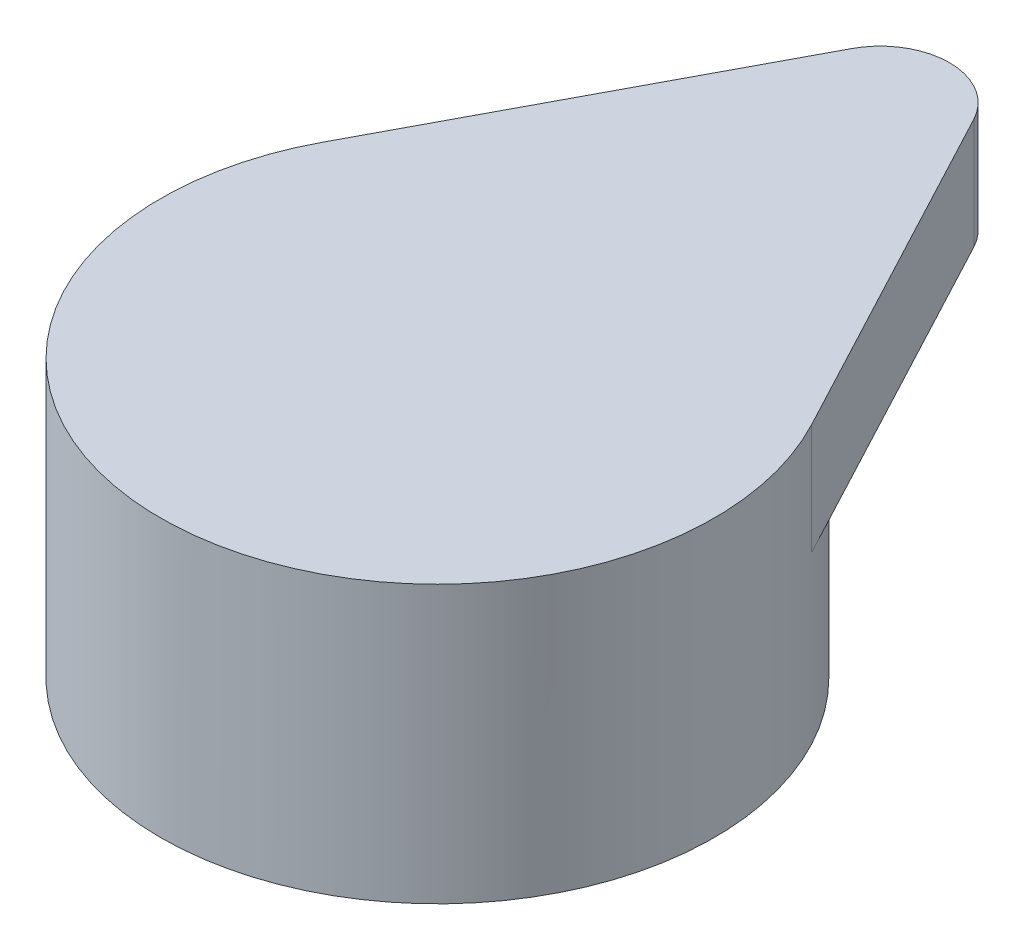
from build123d import *

# Parameters (mm, degrees)
SKETCH1_R           = 5.000000033
SKETCH1_R_2         = 3
BOSS_EXTRUDE1_DEPTH = 3
BOSS_EXTRUDE2_DEPTH = 2


with BuildPart() as part:
    # Sketch1 → Boss-Extrude1 (new body)
    with BuildSketch(Plane(origin=(0, 0, 0), x_dir=(1, 0, 0), z_dir=(0, 1, 0))):
        Circle(SKETCH1_R)
        Circle(SKETCH1_R_2, mode=Mode.SUBTRACT)
    extrude(amount=BOSS_EXTRUDE1_DEPTH)

    # Sketch2 → Boss-Extrude2 (add)
    with BuildSketch(Plane(origin=(0, 3, 0), x_dir=(1, 0, 0), z_dir=(0, 1, 0))):
        with BuildLine():
            Line((4.416654416, 2.343750007), (1.104163597, 8.585937596))
            ThreePointArc((1.104163597, 8.585937596), (0, 9.250000098), (-1.104163597, 8.585937596))
            Line((-1.104163597, 8.585937596), (-4.416654416, 2.343750007))
            ThreePointArc((-4.416654416, 2.343750007), (0, -5.000000033), (4.416654416, 2.343750007))
        make_face()
    extrude(amount=BOSS_EXTRUDE2_DEPTH)


solid = part.part
